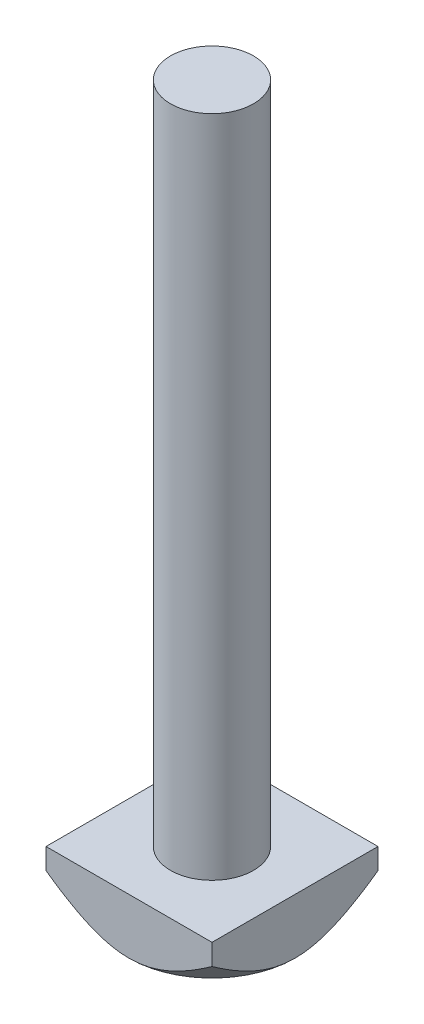
from build123d import *

# Parameters (mm, degrees)
SKETCH1_R           = 6
BOSS_EXTRUDE1_DEPTH = 96
SKETCH11_W          = 24
SKETCH11_H          = 24
BOSS_EXTRUDE5_DEPTH = 8
SKETCH12_OUTSIDE_W  = 63.88
SKETCH12_OUTSIDE_H  = 63.88
SKETCH12_OUTSIDE_R  = 12
CUT_EXTRUDE3_DEPTH  = 8
CUT_EXTRUDE3_TAPER  = 45


with BuildPart() as part:
    # Sketch1 → Boss-Extrude1 (new body)
    with BuildSketch(Plane(origin=(0, 0, 0), x_dir=(1, 0, 0), z_dir=(0, 1, 0))):
        Circle(SKETCH1_R)
    extrude(amount=BOSS_EXTRUDE1_DEPTH)

    # Sketch11 → Boss-Extrude5 (add)
    with BuildSketch(Plane.XZ):
        Rectangle(SKETCH11_W, SKETCH11_H)
    extrude(amount=BOSS_EXTRUDE5_DEPTH)

    # Sketch12 outside → Cut-Extrude3 (cut)
    with BuildSketch(Plane(origin=(0, -8, 0), x_dir=(-1, 0, 0), z_dir=(0, -1, 0))):
        Rectangle(SKETCH12_OUTSIDE_W, SKETCH12_OUTSIDE_H)
        Circle(SKETCH12_OUTSIDE_R, mode=Mode.SUBTRACT)
    extrude(amount=-CUT_EXTRUDE3_DEPTH, taper=CUT_EXTRUDE3_TAPER, mode=Mode.SUBTRACT)


solid = part.part
